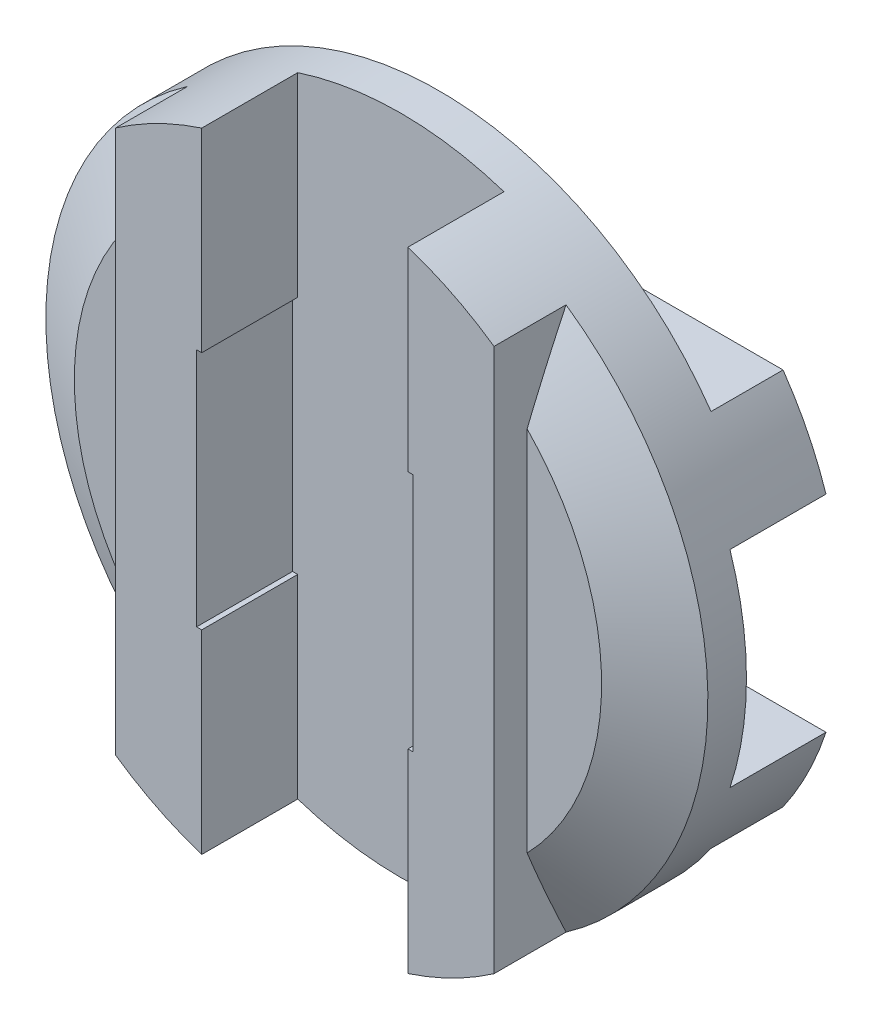
from build123d import *

# Parameters (mm, degrees)
SKETCH1_R             = 12.7
BOSS_EXTRUDE1_DEPTH   = 3.9624
SKETCH2_W             = 7.9121
SKETCH2_H             = 25.4
CUT_EXTRUDE1_DEPTH    = 3.683
SKETCH3_W             = 25.4
SKETCH3_H             = 7.9121
CUT_EXTRUDE2_DEPTH    = 3.683
SKETCH4_W             = 5.44195
SKETCH4_H             = 25.4
CUT_EXTRUDE3_DEPTH    = 1.27
SKETCH5_W             = 25.4
SKETCH5_H             = 5.44195
CUT_EXTRUDE4_DEPTH    = 1.27
CHAMFER1_SIZE         = 2.58492625
CHAMFER1_SIZE2        = 1.492407866
CHAMFER1_PART_2_SIZE  = 2.58492625
CHAMFER1_PART_2_SIZE2 = 1.492407866
CHAMFER1_PART_3_SIZE  = 2.58492625
CHAMFER1_PART_3_SIZE2 = 1.492407866
CHAMFER1_PART_4_SIZE  = 2.58492625
CHAMFER1_PART_4_SIZE2 = 1.492407866
SKETCH6_W             = 8.307705
SKETCH6_H             = 9.2075
CUT_EXTRUDE5_DEPTH    = 3.683
SKETCH7_W             = 9.2075
SKETCH7_H             = 8.307705
CUT_EXTRUDE6_DEPTH    = 3.683


with BuildPart() as part:
    # Sketch1 → Boss-Extrude1 (new body, symmetric)
    with BuildSketch(Plane.XY):
        Circle(SKETCH1_R)
    extrude(amount=BOSS_EXTRUDE1_DEPTH, both=True)

    # Sketch2 → Cut-Extrude1 (cut)
    with BuildSketch(Plane.XY.offset(3.9624)):
        Rectangle(SKETCH2_W, SKETCH2_H)
    extrude(amount=-CUT_EXTRUDE1_DEPTH, mode=Mode.SUBTRACT)

    # Sketch3 → Cut-Extrude2 (cut)
    with BuildSketch(Plane(origin=(0, 0, -3.9624), x_dir=(-1, 0, 0), z_dir=(0, 0, -1))):
        Rectangle(SKETCH3_W, SKETCH3_H)
    extrude(amount=-CUT_EXTRUDE2_DEPTH, mode=Mode.SUBTRACT)

    # Sketch4 → Cut-Extrude3 (cut)
    with BuildSketch(Plane.XY.offset(3.9624)):
        with Locations((9.979025, 0)):
            Rectangle(SKETCH4_W, SKETCH4_H)
        with Locations((-9.979025, 0)):
            Rectangle(SKETCH4_W, SKETCH4_H)
    extrude(amount=-CUT_EXTRUDE3_DEPTH, mode=Mode.SUBTRACT)

    # Sketch5 → Cut-Extrude4 (cut)
    with BuildSketch(Plane(origin=(0, 0, -3.9624), x_dir=(-1, 0, 0), z_dir=(0, 0, -1))):
        with Locations((0, 9.979025)):
            Rectangle(SKETCH5_W, SKETCH5_H)
        with Locations((0, -9.979025)):
            Rectangle(SKETCH5_W, SKETCH5_H)
    extrude(amount=-CUT_EXTRUDE4_DEPTH, mode=Mode.SUBTRACT)

    # Chamfer1
    chamfer1_edges = [part.edges().sort_by_distance(p)[0] for p in [
        (0, 12.7, -2.6924),
    ]]
    chamfer1_side = [part.faces().sort_by_distance(p)[0] for p in [
        (0, 9.480522033, -2.6924),
    ]]
    chamfer(chamfer1_edges, length=CHAMFER1_SIZE, length2=CHAMFER1_SIZE2, reference=chamfer1_side[0])

    # Chamfer1 part 2
    chamfer1_part_2_edges = [part.edges().sort_by_distance(p)[0] for p in [
        (0, -12.7, -2.6924),
    ]]
    chamfer1_part_2_side = [part.faces().sort_by_distance(p)[0] for p in [
        (0, -9.480522033, -2.6924),
    ]]
    chamfer(chamfer1_part_2_edges, length=CHAMFER1_PART_2_SIZE, length2=CHAMFER1_PART_2_SIZE2, reference=chamfer1_part_2_side[0])

    # Chamfer1 part 3
    chamfer1_part_3_edges = [part.edges().sort_by_distance(p)[0] for p in [
        (11.257602653, -5.8784677, 2.6924),
    ]]
    chamfer1_part_3_side = [part.faces().sort_by_distance(p)[0] for p in [
        (9.480522033, 0, 2.6924),
    ]]
    chamfer(chamfer1_part_3_edges, length=CHAMFER1_PART_3_SIZE, length2=CHAMFER1_PART_3_SIZE2, reference=chamfer1_part_3_side[0])

    # Chamfer1 part 4
    chamfer1_part_4_edges = [part.edges().sort_by_distance(p)[0] for p in [
        (-12.7, 0, 2.6924),
    ]]
    chamfer1_part_4_side = [part.faces().sort_by_distance(p)[0] for p in [
        (-9.480522033, 0, 2.6924),
    ]]
    chamfer(chamfer1_part_4_edges, length=CHAMFER1_PART_4_SIZE, length2=CHAMFER1_PART_4_SIZE2, reference=chamfer1_part_4_side[0])

    # Sketch6 → Cut-Extrude5 (cut)
    with BuildSketch(Plane.XY.offset(3.9624)):
        Rectangle(SKETCH6_W, SKETCH6_H)
    extrude(amount=-CUT_EXTRUDE5_DEPTH, mode=Mode.SUBTRACT)

    # Sketch7 → Cut-Extrude6 (cut)
    with BuildSketch(Plane(origin=(0, 0, -3.9624), x_dir=(-1, 0, 0), z_dir=(0, 0, -1))):
        Rectangle(SKETCH7_W, SKETCH7_H)
    extrude(amount=-CUT_EXTRUDE6_DEPTH, mode=Mode.SUBTRACT)


solid = part.part
